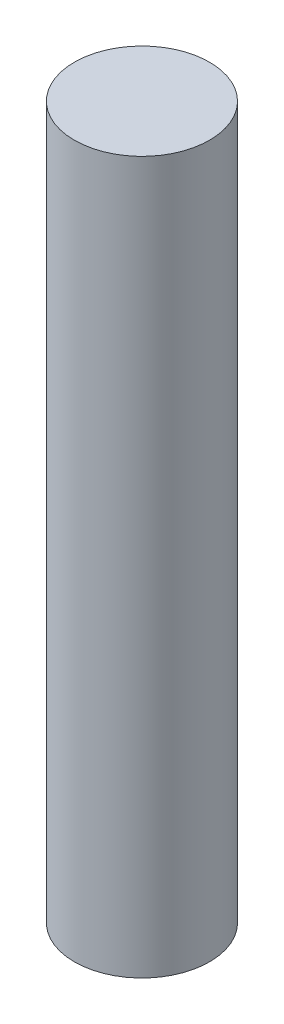
from build123d import *

# Parameters (mm, degrees)
SKETCH1_R           = 4.826
BOSS_EXTRUDE1_DEPTH = 50.8


with BuildPart() as part:
    # Sketch1 → Boss-Extrude1 (new body)
    with BuildSketch(Plane(origin=(0, 0, 0), x_dir=(1, 0, 0), z_dir=(0, 1, 0))):
        with Locations((1.949810434, -0.24891883)):
            Circle(SKETCH1_R)
    extrude(amount=BOSS_EXTRUDE1_DEPTH)


solid = part.part
